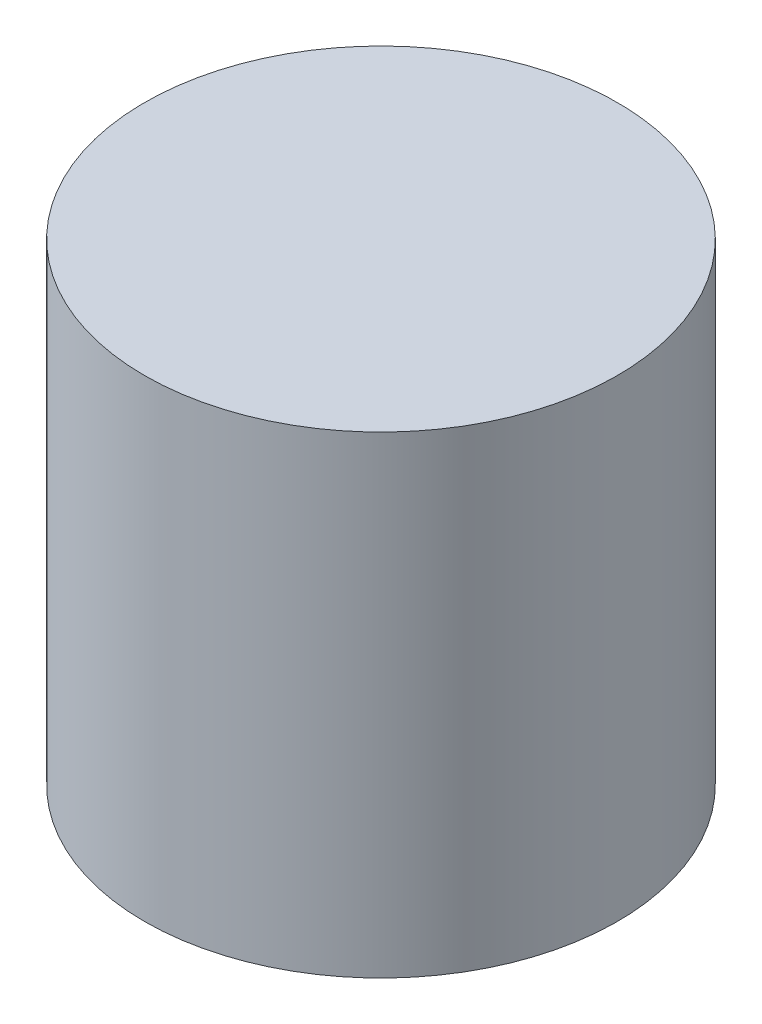
from build123d import *

# Parameters (mm, degrees)
SKETCH1_R           = 3.175
BOSS_EXTRUDE1_DEPTH = 6.35


with BuildPart() as part:
    # Sketch1 → Boss-Extrude1 (new body)
    with BuildSketch(Plane(origin=(0, 0, 0), x_dir=(1, 0, 0), z_dir=(0, 1, 0))):
        Circle(SKETCH1_R)
    extrude(amount=BOSS_EXTRUDE1_DEPTH)


solid = part.part
